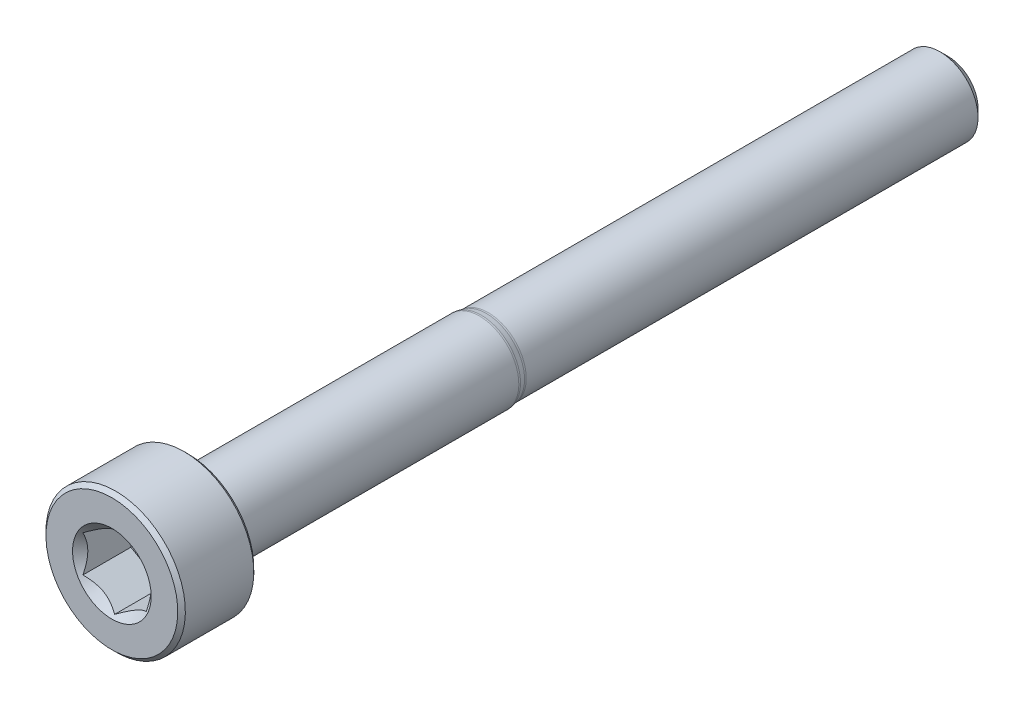
from build123d import *

# Parameters (mm, degrees)
CUT_EXTRUDE1_DEPTH = 2
SKETCH4_R          = 1.551628848
CUT_EXTRUDE2_DEPTH = 2
CUT_EXTRUDE2_DRAFT = -45


with BuildPart() as part:
    # Sketch2 → Revolve1 (revolve)
    with BuildSketch(Plane(origin=(0, 0, 0), x_dir=(0, 0, -1), z_dir=(1, 0, 0))):
        with BuildLine():
            Line((-16.5, 0), (-16.5, 2.6))
            Line((-16.5, 2.6), (-16.35, 2.75))
            Line((-16.35, 2.75), (-13.65, 2.75))
            Line((-13.65, 2.75), (-13.5, 2.6))
            Line((-13.5, 2.6), (-13.5, 1.704126588))
            ThreePointArc((-13.5, 1.704126588), (-13.456066017, 1.598060571), (-13.35, 1.554126588))
            Line((-13.35, 1.554126588), (-1.996547008, 1.554126588))
            ThreePointArc((-1.996547008, 1.554126588), (-1.959790581, 1.55232086), (-1.923388138, 1.546921068))
            Line((-1.923388138, 1.546921068), (-1.723724594, 1.50720552))
            ThreePointArc((-1.723724594, 1.50720552), (-1.687322151, 1.501805727), (-1.650565724, 1.5))
            Line((-1.650565724, 1.5), (16.175240474, 1.5))
            Line((16.175240474, 1.5), (16.5, 1.175240474))
            Line((16.5, 1.175240474), (16.5, 0))
            Line((16.5, 0), (-16.5, 0))
        make_face()
    revolve(axis=Axis((0, 0, -16.5), (0, 0, 1)))

    # Sketch3 → Cut-Extrude1 (cut)
    with BuildSketch(Plane.XY.offset(16.5)):
        Polygon((1.25, -0.721687836), (1.25, 0.721687836), (0, 1.443375673), (-1.25, 0.721687836), (-1.25, -0.721687836), (0, -1.443375673), align=None)
    extrude(amount=-CUT_EXTRUDE1_DEPTH, mode=Mode.SUBTRACT)


with BuildPart() as cut_extrude2_tool:
    # Sketch4 → Cut-Extrude2 (with draft: the straight prism first)
    with BuildSketch(Plane.XY.offset(16.5)):
        Circle(SKETCH4_R)
    extrude(amount=-CUT_EXTRUDE2_DEPTH)
    # Cut-Extrude2: the draft: its side faces are tilted about the plane it starts from
    cut_extrude2_sides = [cut_extrude2_tool.faces().sort_by_distance(p)[0] for p in [
        (-1.551628848, 0, 15.5),
    ]]
    draft(cut_extrude2_sides, Plane.XY.offset(16.5), CUT_EXTRUDE2_DRAFT)


with BuildPart() as part_1:
    add(part.part)

    # Cut-Extrude2: cut by cut_extrude2_tool
    add(cut_extrude2_tool.part, mode=Mode.SUBTRACT)


solid = part_1.part
